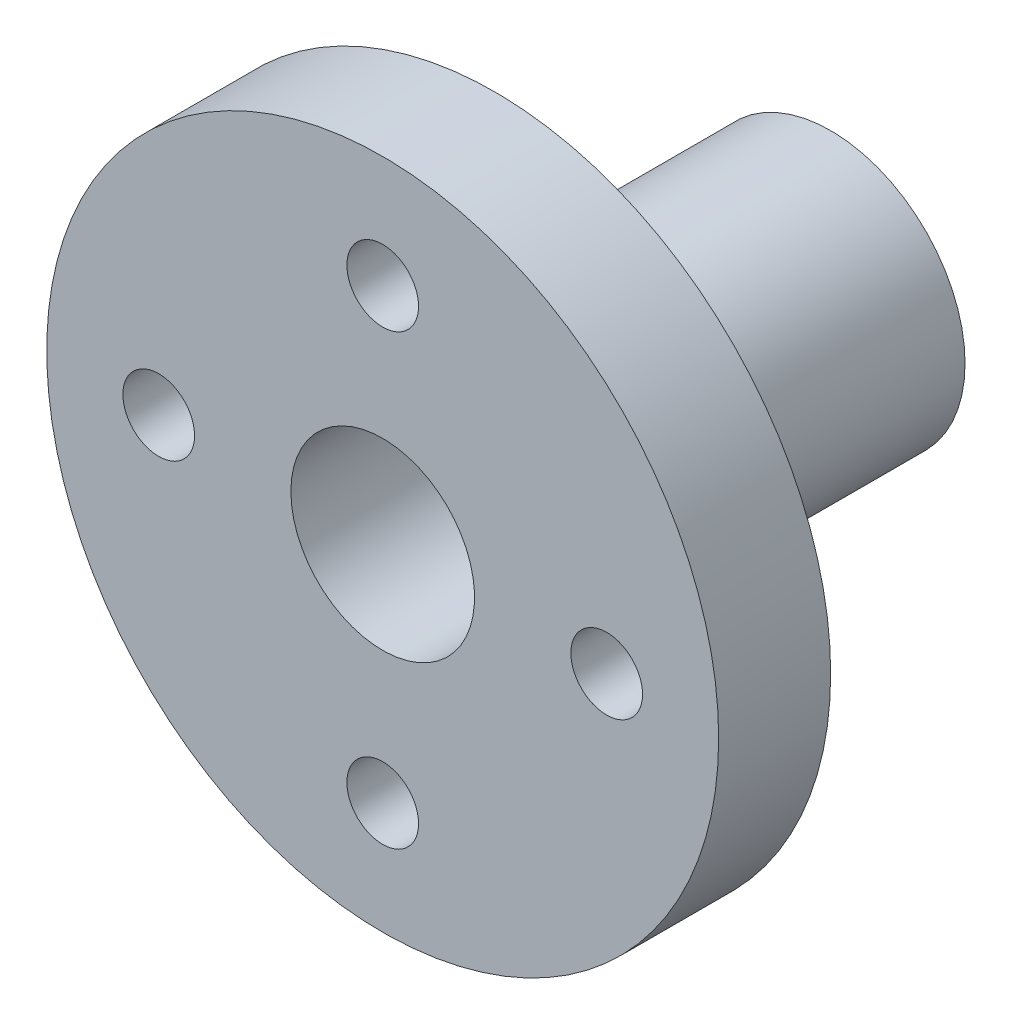
from build123d import *

# Parameters (mm, degrees)
SKETCH_1_R          = 15
SKETCH_1_R_2        = 1.6
EXTRUDE_1_DEPTH     = 5
SKETCH_2_R          = 6
EXTRUDE_2_DEPTH     = 15
SKETCH_3_R          = 4.1
CUT_EXTRUDE_1_DEPTH = 21
SKETCH_4_R          = 1.6
CUT_EXTRUDE_2_DEPTH = 15


with BuildPart() as part:
    # 草图1 → 凸台-拉伸1 (new body)
    with BuildSketch(Plane.XY):
        with Locations((-1.893979513, 4.311637078)):
            Circle(SKETCH_1_R)
        with Locations((-1.893979513, 14.311637078)):
            Circle(SKETCH_1_R_2, mode=Mode.SUBTRACT)
        with Locations((8.106020487, 4.311637078)):
            Circle(SKETCH_1_R_2, mode=Mode.SUBTRACT)
        with Locations((-1.893979513, -5.688362922)):
            Circle(SKETCH_1_R_2, mode=Mode.SUBTRACT)
        with Locations((-11.893979513, 4.311637078)):
            Circle(SKETCH_1_R_2, mode=Mode.SUBTRACT)
    extrude(amount=EXTRUDE_1_DEPTH)

    # 草图2 → 凸台-拉伸2 (add)
    with BuildSketch(Plane.XY):
        with Locations((-1.893979513, 4.311637078)):
            Circle(SKETCH_2_R)
    extrude(amount=-EXTRUDE_2_DEPTH)

    # 草图3 → 切除-拉伸1 (cut, through all)
    with BuildSketch(Plane(origin=(0, 0, -15), x_dir=(-1, 0, 0), z_dir=(0, 0, -1))):
        with Locations((1.893979513, 4.311637078)):
            Circle(SKETCH_3_R)
    extrude(amount=-CUT_EXTRUDE_1_DEPTH, mode=Mode.SUBTRACT)

    # 草图4 → 切除-拉伸2 (cut, symmetric)
    with BuildSketch(Plane(origin=(0, 0, 0), x_dir=(1, 0, 0), z_dir=(0, 1, 0))):
        with Locations((-1.893979513, 5.299041656)):
            Circle(SKETCH_4_R)
    extrude(amount=CUT_EXTRUDE_2_DEPTH, both=True, mode=Mode.SUBTRACT)


solid = part.part
